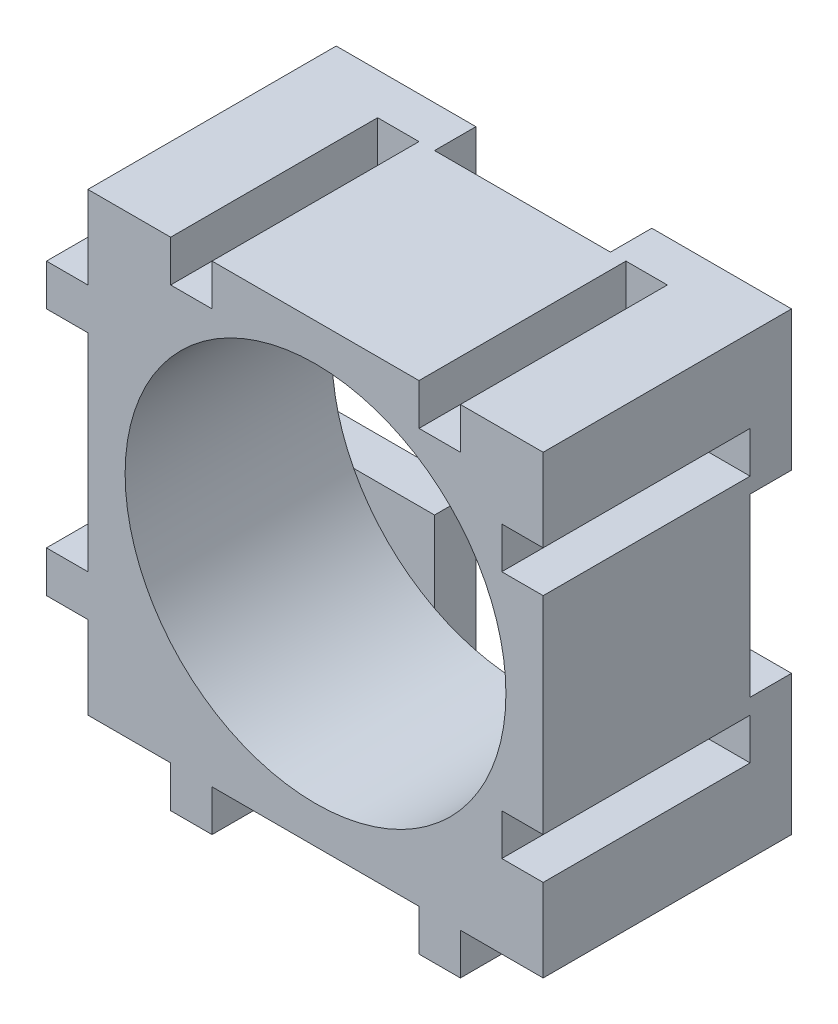
from build123d import *

# Parameters (mm, degrees)
SKETCH1_W           = 22
SKETCH1_H           = 22
BOSS_EXTRUDE1_DEPTH = 10
SKETCH3_W           = 2
SKETCH3_H           = 10
BOSS_EXTRUDE2_DEPTH = 2
SKETCH4_W           = 10
SKETCH4_H           = 2
BOSS_EXTRUDE3_DEPTH = 2
SKETCH5_W           = 10
SKETCH5_H           = 2
CUT_EXTRUDE1_DEPTH  = 2
SKETCH6_W           = 2
SKETCH6_H           = 10
CUT_EXTRUDE2_DEPTH  = 2
SKETCH7_R           = 9.2
CUT_EXTRUDE3_DEPTH  = 11
SKETCH8_W           = 6.75
SKETCH8_H           = 6.75
BOSS_EXTRUDE4_DEPTH = 2
SKETCH9_R           = 1.5
CUT_EXTRUDE6_DEPTH  = 6


with BuildPart() as part:
    # Sketch1 → Boss-Extrude1 (new body)
    with BuildSketch(Plane.XY):
        with Locations((1.600938967, -1.755868545)):
            Rectangle(SKETCH1_W, SKETCH1_H)
    extrude(amount=BOSS_EXTRUDE1_DEPTH)

    # Sketch3 → Boss-Extrude2 (add)
    with BuildSketch(Plane.XZ.offset(12.755868545)):
        with Locations((7.600938967, 5)):
            Rectangle(SKETCH3_W, SKETCH3_H)
        with Locations((-4.399061033, 5)):
            Rectangle(SKETCH3_W, SKETCH3_H)
    extrude(amount=BOSS_EXTRUDE2_DEPTH)

    # Sketch4 → Boss-Extrude3 (add)
    with BuildSketch(Plane.ZY.offset(9.399061033)):
        with Locations((5, 4.244131455)):
            Rectangle(SKETCH4_W, SKETCH4_H)
        with Locations((5, -7.755868545)):
            Rectangle(SKETCH4_W, SKETCH4_H)
    extrude(amount=BOSS_EXTRUDE3_DEPTH)

    # Sketch5 → Cut-Extrude1 (cut)
    with BuildSketch(Plane(origin=(12.600938967, 0, 0), x_dir=(0, 0, -1), z_dir=(1, 0, 0))):
        with Locations((-5, 4.244131455)):
            Rectangle(SKETCH5_W, SKETCH5_H)
        with Locations((-5, -7.755868545)):
            Rectangle(SKETCH5_W, SKETCH5_H)
    extrude(amount=-CUT_EXTRUDE1_DEPTH, mode=Mode.SUBTRACT)

    # Sketch6 → Cut-Extrude2 (cut)
    with BuildSketch(Plane(origin=(0, 9.244131455, 0), x_dir=(1, 0, 0), z_dir=(0, 1, 0))):
        with Locations((-4.399061033, -5)):
            Rectangle(SKETCH6_W, SKETCH6_H)
        with Locations((7.600938967, -5)):
            Rectangle(SKETCH6_W, SKETCH6_H)
    extrude(amount=-CUT_EXTRUDE2_DEPTH, mode=Mode.SUBTRACT)

    # Sketch7 → Cut-Extrude3 (cut, through all)
    with BuildSketch(Plane.XY.offset(10)):
        with Locations((1.600938967, -1.755868545)):
            Circle(SKETCH7_R)
    extrude(amount=-CUT_EXTRUDE3_DEPTH, mode=Mode.SUBTRACT)

    # Sketch8 → Boss-Extrude4 (add)
    with BuildSketch(Plane(origin=(0, 0, 0), x_dir=(-1, 0, 0), z_dir=(0, 0, -1))):
        with Locations((6.024061033, 5.869131455)):
            Rectangle(SKETCH8_W, SKETCH8_H)
        with Locations((-9.225938967, 5.869131455)):
            Rectangle(SKETCH8_W, SKETCH8_H)
        with Locations((-9.225938967, -9.380868545)):
            Rectangle(SKETCH8_W, SKETCH8_H)
        with Locations((6.024061033, -9.380868545)):
            Rectangle(SKETCH8_W, SKETCH8_H)
    extrude(amount=BOSS_EXTRUDE4_DEPTH)

    # Sketch9 → Cut-Extrude6 (cut)
    with BuildSketch(Plane(origin=(0, 0, -2), x_dir=(-1, 0, 0), z_dir=(0, 0, -1))):
        with Locations((7.399061033, -10.755868545)):
            Circle(SKETCH9_R)
        with Locations((-10.600938967, -10.755868545)):
            Circle(SKETCH9_R)
        with Locations((7.399061033, 7.244131455)):
            Circle(SKETCH9_R)
        with Locations((-10.600938967, 7.244131455)):
            Circle(SKETCH9_R)
    extrude(amount=-CUT_EXTRUDE6_DEPTH, mode=Mode.SUBTRACT)


solid = part.part
